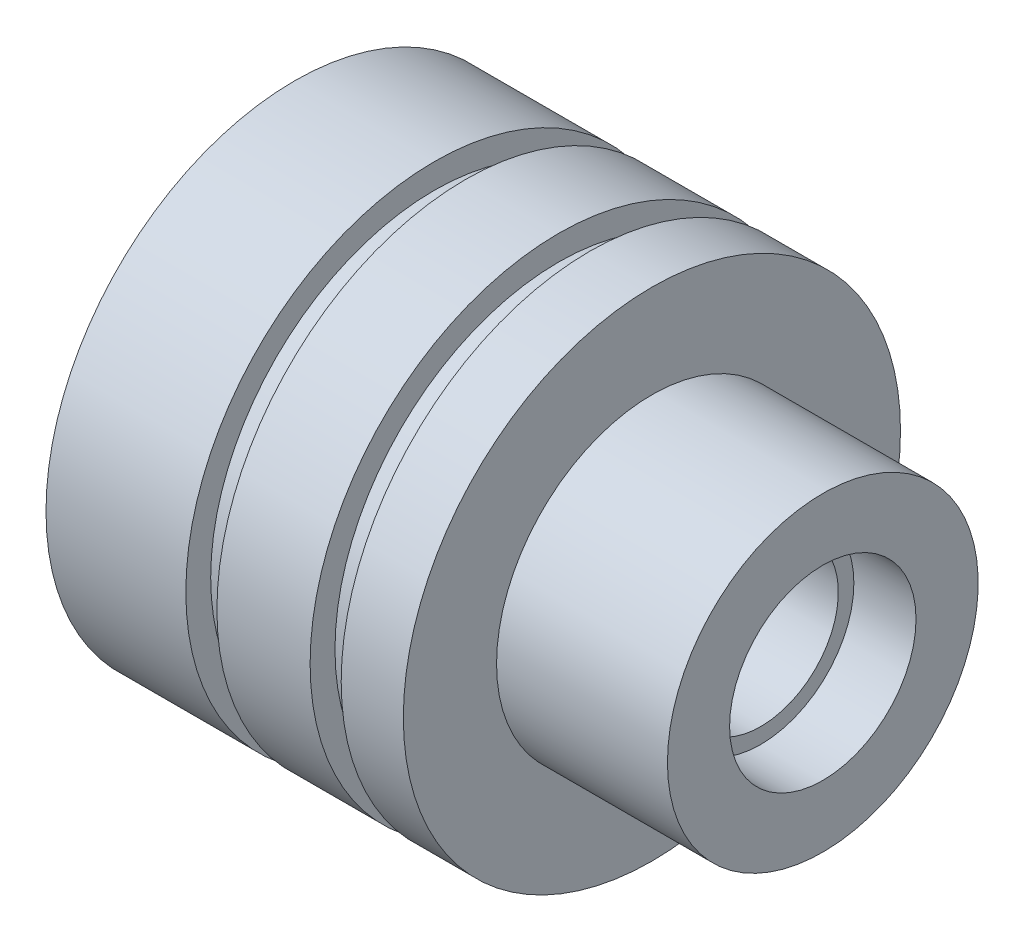
from build123d import *


with BuildPart() as part:
    # Skizze1 → Rotation1 (revolve)
    with BuildSketch(Plane.XY):
        Polygon((0, 8), (0, 5), (5.6, 5), (5.6, 2.5), (15, 2.5), (15, 3), (17, 3), (17, 5), (11.5, 5), (11.5, 8), (9.5, 8), (9.5, 7.2), (8.5, 7.2), (8.5, 8), (5.5, 8), (5.5, 7.2), (4.5, 7.2), (4.5, 8), align=None)
    revolve(axis=Axis((0, 0, 0), (1, 0, 0)))


solid = part.part
